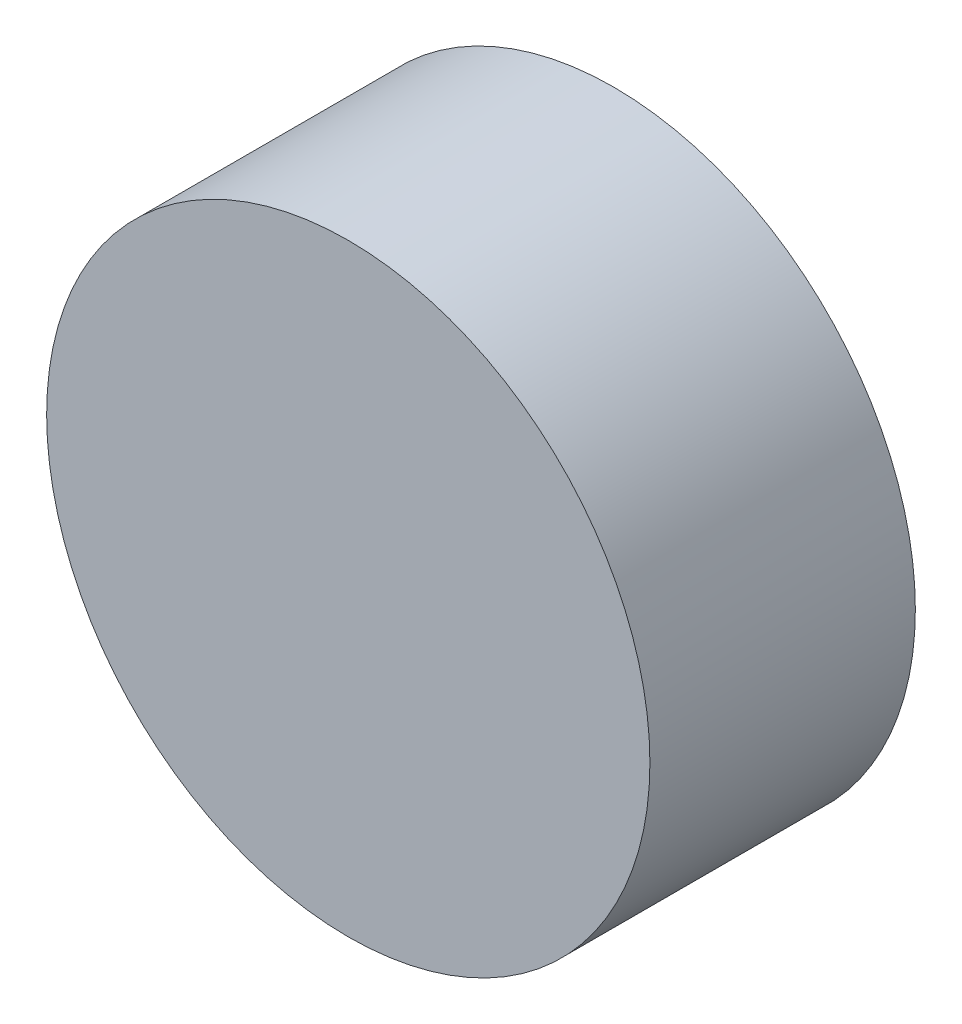
from build123d import *

# Parameters (mm, degrees)
SKETCH1_R           = 12.5
BOSS_EXTRUDE1_DEPTH = 11


with BuildPart() as part:
    # Sketch1 → Boss-Extrude1 (new body)
    with BuildSketch(Plane.XY):
        Circle(SKETCH1_R)
    extrude(amount=BOSS_EXTRUDE1_DEPTH)


solid = part.part
